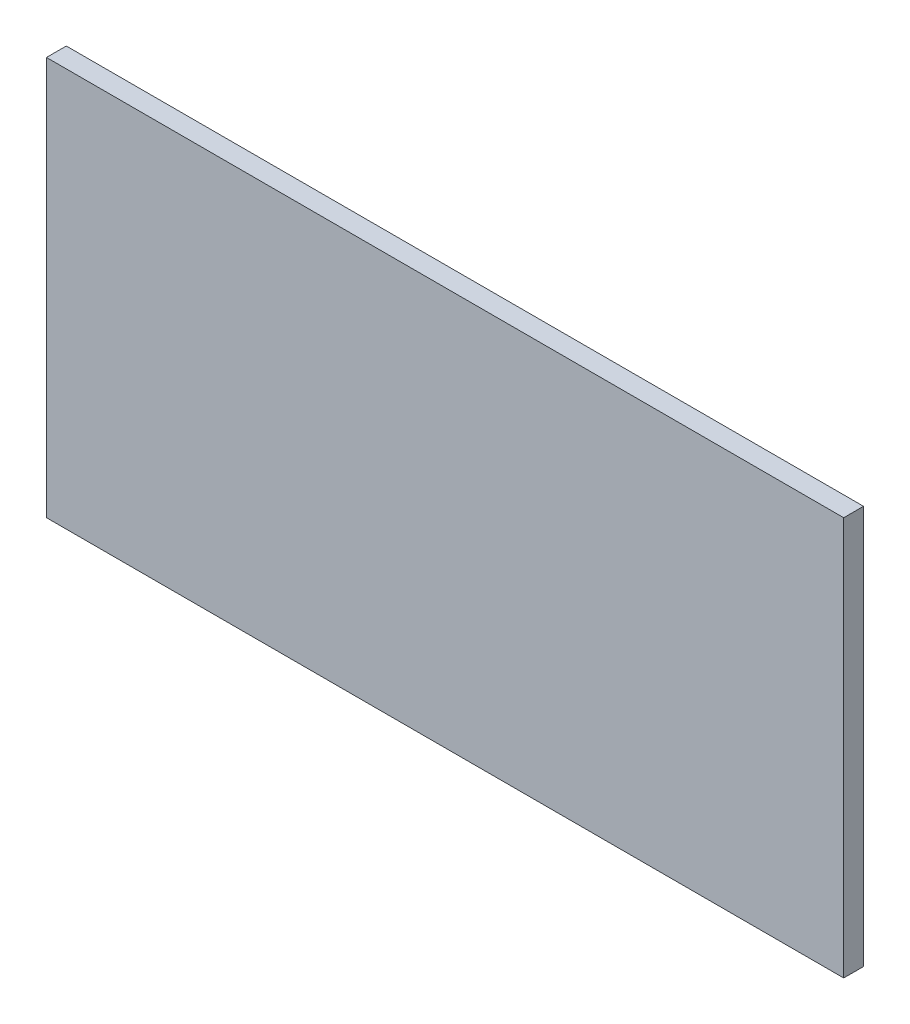
from build123d import *

# Parameters (mm, degrees)
SKETCH1_W           = 181
SKETCH1_H           = 90.5
BOSS_EXTRUDE1_DEPTH = 2.25


with BuildPart() as part:
    # Sketch1 → Boss-Extrude1 (new body, symmetric)
    with BuildSketch(Plane.XY):
        with Locations((0, -45.25)):
            Rectangle(SKETCH1_W, SKETCH1_H)
    extrude(amount=BOSS_EXTRUDE1_DEPTH, both=True)


solid = part.part
